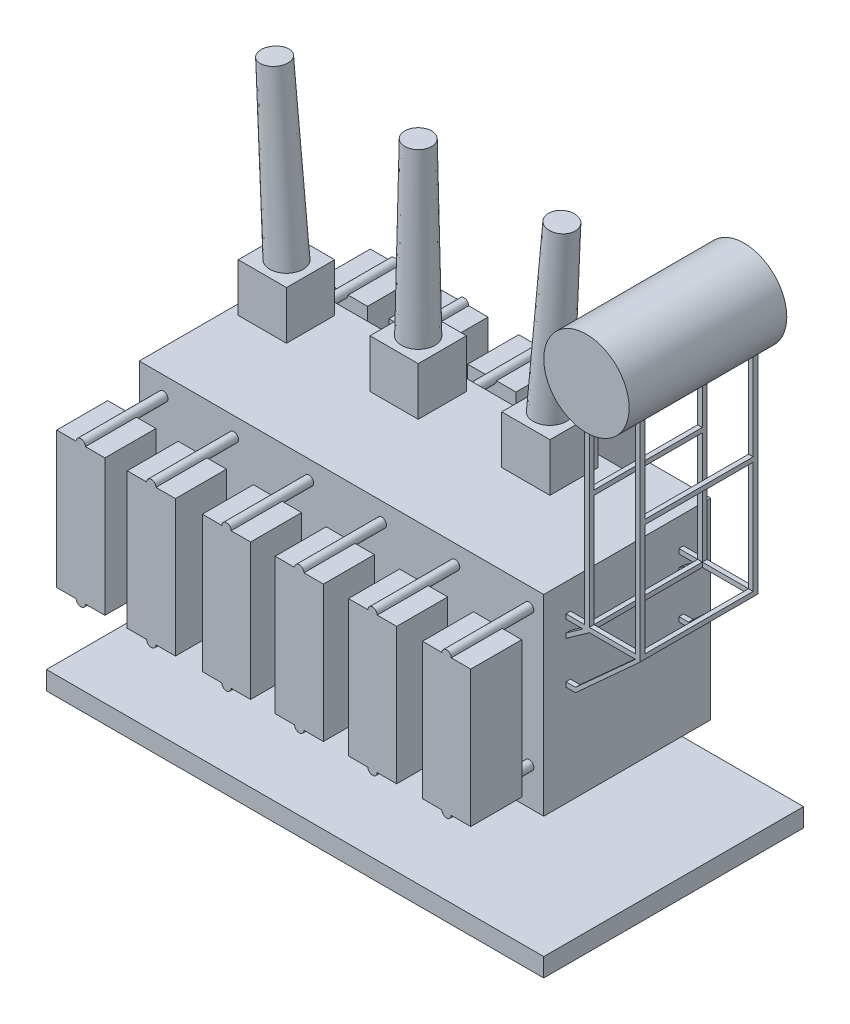
from build123d import *

# Parameters (mm, degrees)
BOSS_EXTRUDE1_DEPTH   = 1800
SKETCH3_W             = 3700
SKETCH3_H             = 199.704337058
CUT_EXTRUDE1_DEPTH    = 1800
SKETCH5_W             = 3700
SKETCH5_H             = 199.704337058
CUT_EXTRUDE2_DEPTH    = 1800
SKETCH6_W             = 520
SKETCH6_H             = 550
BOSS_EXTRUDE2_DEPTH   = 1470
BOSS_EXTRUDE2_2_DEPTH = 1470
BOSS_EXTRUDE2_3_DEPTH = 1470
BOSS_EXTRUDE2_4_DEPTH = 1470
BOSS_EXTRUDE2_5_DEPTH = 1470
BOSS_EXTRUDE2_6_DEPTH = 1470
SKETCH7_W             = 520
SKETCH7_H             = 550
BOSS_EXTRUDE3_DEPTH   = 1470
BOSS_EXTRUDE3_2_DEPTH = 1470
BOSS_EXTRUDE3_3_DEPTH = 1470
BOSS_EXTRUDE3_4_DEPTH = 1470
CUT_EXTRUDE3_DEPTH    = 2761
BOSS_EXTRUDE4_DEPTH   = 200
BOSS_EXTRUDE5_START   = -890
SKETCH9_R             = 50
BOSS_EXTRUDE5_DEPTH   = 890
BOSS_EXTRUDE6_START   = -890
SKETCH12_R            = 50
BOSS_EXTRUDE6_DEPTH   = 890
BOSS_EXTRUDE7_REACH   = 6057.333
SKETCH13_R            = 50
SKETCH15_W            = 520
SKETCH15_H            = 520
SKETCH15_W_2          = 519.994242444
SKETCH15_H_2          = 519.994242444
BOSS_EXTRUDE8_DEPTH   = 520
SKETCH20_R            = 460
BOSS_EXTRUDE9_DEPTH   = 1700
SKETCH21_W            = 50
SKETCH21_H            = 50
BOSS_EXTRUDE10_DEPTH  = 800
BOSS_EXTRUDE12_DEPTH  = 50
BOSS_EXTRUDE13_DEPTH  = 50
BOSS_EXTRUDE14_REACH  = 7096.951
SKETCH26_W            = 50
SKETCH26_H            = 50.276711992
SKETCH26_H_2          = 50
BOSS_EXTRUDE15_REACH  = 7319.411
SKETCH27_W            = 50
SKETCH27_H            = 50
BOSS_EXTRUDE16_REACH  = 7319.411
SKETCH29_W            = 50
SKETCH29_H            = 50
SKETCH30_W            = 5360
SKETCH30_H            = 2800
BOSS_EXTRUDE17_DEPTH  = 200


with BuildPart() as part:
    # Sketch2 → Boss-Extrude1 (new body)
    with BuildSketch(Plane.XY):
        Polygon((-4370.870959495, 2277.123604061), (-10.870959495, 2277.123604061), (-10.870959495, 247.123604061), (-670.870959495, 247.123604061), (-670.870959495, 7.123604061), (-4370.870959495, 7.123604061), align=None)
    extrude(amount=BOSS_EXTRUDE1_DEPTH)

    # Sketch3 → Cut-Extrude1 (cut)
    with BuildSketch(Plane(origin=(0, 2277.123604061, 0), x_dir=(1, 0, 0), z_dir=(0, 1, 0))):
        with Locations((-2520.870959495, -99.852168529)):
            Rectangle(SKETCH3_W, SKETCH3_H)
    extrude(amount=-CUT_EXTRUDE1_DEPTH, mode=Mode.SUBTRACT)

    # Sketch5 → Cut-Extrude2 (cut)
    with BuildSketch(Plane(origin=(0, 477.123604061, 0), x_dir=(1, 0, 0), z_dir=(0, 1, 0))):
        with Locations((-2520.870959495, -99.852168529)):
            Rectangle(SKETCH5_W, SKETCH5_H)
    extrude(amount=-CUT_EXTRUDE2_DEPTH, mode=Mode.SUBTRACT)

    # Sketch10 → Cut-Extrude3 (cut)
    with BuildSketch(Plane.XY.offset(1800)):
        Polygon((-4370.870959495, 7.123604061), (-4370.870959495, 207.123604061), (-670.870959495, 207.123604061), (-670.870959495, 407.123604061), (-10.870959495, 407.123604061), (-10.870959495, -217.1470637), (-4370.870959495, -217.1470637), align=None)
    extrude(amount=-CUT_EXTRUDE3_DEPTH, mode=Mode.SUBTRACT)

    # Sketch11 → Boss-Extrude4 (add)
    with BuildSketch(Plane(origin=(0, 2277.123604061, 0), x_dir=(1, 0, 0), z_dir=(0, 1, 0))):
        Polygon((-4370.870959495, -199.704337058), (-670.870959495, -199.704337058), (-670.870959495, 0), (-10.870959495, 0), (-10.870959495, -1800), (-4370.870959495, -1800), align=None)
    extrude(amount=BOSS_EXTRUDE4_DEPTH)



with BuildPart() as body_2:
    # Sketch6 → Boss-Extrude2 (new body)
    with BuildSketch(Plane(origin=(0, 2277.123604061, 0), x_dir=(1, 0, 0), z_dir=(0, 1, 0))):
        with Locations((-4110.870959495, -2415)):
            Rectangle(SKETCH6_W, SKETCH6_H)
    extrude(amount=-BOSS_EXTRUDE2_DEPTH)


with BuildPart() as body_3:
    # Sketch6 → Boss-Extrude2 2 (new body)
    with BuildSketch(Plane(origin=(0, 2277.123604061, 0), x_dir=(1, 0, 0), z_dir=(0, 1, 0))):
        with Locations((-3350.870959495, -2415)):
            Rectangle(SKETCH6_W, SKETCH6_H)
    extrude(amount=-BOSS_EXTRUDE2_2_DEPTH)


with BuildPart() as body_4:
    # Sketch6 → Boss-Extrude2 3 (new body)
    with BuildSketch(Plane(origin=(0, 2277.123604061, 0), x_dir=(1, 0, 0), z_dir=(0, 1, 0))):
        with Locations((-2540.870959495, -2415)):
            Rectangle(SKETCH6_W, SKETCH6_H)
    extrude(amount=-BOSS_EXTRUDE2_3_DEPTH)


with BuildPart() as body_5:
    # Sketch6 → Boss-Extrude2 4 (new body)
    with BuildSketch(Plane(origin=(0, 2277.123604061, 0), x_dir=(1, 0, 0), z_dir=(0, 1, 0))):
        with Locations((-1755.870959495, -2415)):
            Rectangle(SKETCH6_W, SKETCH6_H)
    extrude(amount=-BOSS_EXTRUDE2_4_DEPTH)


with BuildPart() as body_6:
    # Sketch6 → Boss-Extrude2 5 (new body)
    with BuildSketch(Plane(origin=(0, 2277.123604061, 0), x_dir=(1, 0, 0), z_dir=(0, 1, 0))):
        with Locations((-965.870959495, -2415)):
            Rectangle(SKETCH6_W, SKETCH6_H)
    extrude(amount=-BOSS_EXTRUDE2_5_DEPTH)


with BuildPart() as body_7:
    # Sketch6 → Boss-Extrude2 6 (new body)
    with BuildSketch(Plane(origin=(0, 2277.123604061, 0), x_dir=(1, 0, 0), z_dir=(0, 1, 0))):
        with Locations((-167.870959495, -2415)):
            Rectangle(SKETCH6_W, SKETCH6_H)
    extrude(amount=-BOSS_EXTRUDE2_6_DEPTH)


with BuildPart() as body_8:
    # Sketch7 → Boss-Extrude3 (new body)
    with BuildSketch(Plane(origin=(0, 2277.123604061, 0), x_dir=(1, 0, 0), z_dir=(0, 1, 0))):
        with Locations((-4110.870959495, 415.295662942)):
            Rectangle(SKETCH7_W, SKETCH7_H)
    extrude(amount=-BOSS_EXTRUDE3_DEPTH)


with BuildPart() as body_9:
    # Sketch7 → Boss-Extrude3 2 (new body)
    with BuildSketch(Plane(origin=(0, 2277.123604061, 0), x_dir=(1, 0, 0), z_dir=(0, 1, 0))):
        with Locations((-3360.870959495, 415.295662942)):
            Rectangle(SKETCH7_W, SKETCH7_H)
    extrude(amount=-BOSS_EXTRUDE3_2_DEPTH)


with BuildPart() as body_10:
    # Sketch7 → Boss-Extrude3 3 (new body)
    with BuildSketch(Plane(origin=(0, 2277.123604061, 0), x_dir=(1, 0, 0), z_dir=(0, 1, 0))):
        with Locations((-2510.870959495, 415.295662942)):
            Rectangle(SKETCH7_W, SKETCH7_H)
    extrude(amount=-BOSS_EXTRUDE3_3_DEPTH)


with BuildPart() as body_11:
    # Sketch7 → Boss-Extrude3 4 (new body)
    with BuildSketch(Plane(origin=(0, 2277.123604061, 0), x_dir=(1, 0, 0), z_dir=(0, 1, 0))):
        with Locations((-1770.870959495, 415.295662942)):
            Rectangle(SKETCH7_W, SKETCH7_H)
    extrude(amount=-BOSS_EXTRUDE3_4_DEPTH)


with BuildPart() as part_1:
    add(part.part)

    add(body_2.part)  # Boss-Extrude5 merges body 2

    add(body_3.part)  # Boss-Extrude5 merges body 3

    add(body_4.part)  # Boss-Extrude5 merges body 4

    add(body_5.part)  # Boss-Extrude5 merges body 5

    add(body_6.part)  # Boss-Extrude5 merges body 6

    add(body_7.part)  # Boss-Extrude5 merges body 7
    # Sketch9 → Boss-Extrude5 (add)
    with BuildSketch(Plane.XY.offset(2690).offset(BOSS_EXTRUDE5_START)):
        with Locations((-4110.870959495, 2277.123604061)):
            Circle(SKETCH9_R)
        with Locations((-3350.870959495, 2277.123604061)):
            Circle(SKETCH9_R)
        with Locations((-2540.870959495, 2277.123604061)):
            Circle(SKETCH9_R)
        with Locations((-1755.870959495, 2277.123604061)):
            Circle(SKETCH9_R)
        with Locations((-965.870959495, 2277.123604061)):
            Circle(SKETCH9_R)
        with Locations((-167.870959495, 2277.123604061)):
            Circle(SKETCH9_R)
    extrude(amount=BOSS_EXTRUDE5_DEPTH)


    add(body_8.part)  # Boss-Extrude6 merges body 8

    add(body_9.part)  # Boss-Extrude6 merges body 9

    add(body_10.part)  # Boss-Extrude6 merges body 10

    add(body_11.part)  # Boss-Extrude6 merges body 11
    # Sketch12 → Boss-Extrude6 (add)
    with BuildSketch(Plane(origin=(0, 0, -690.295662942), x_dir=(-1, 0, 0), z_dir=(0, 0, -1)).offset(BOSS_EXTRUDE6_START)):
        with Locations((1770.870959495, 2277.123604061)):
            Circle(SKETCH12_R)
        with Locations((2510.870959495, 2277.123604061)):
            Circle(SKETCH12_R)
        with Locations((3360.870959495, 2277.123604061)):
            Circle(SKETCH12_R)
        with Locations(Location((4110.870959495, 2277.123604061, 0), (0, 0, 180))):
            Circle(SKETCH12_R)
        with Locations(Location((4110.870959495, 807.123604061, 0), (0, 0, 180))):
            Circle(SKETCH12_R)
        with Locations((3360.870959495, 807.123604061)):
            Circle(SKETCH12_R)
        with Locations((2510.870959495, 807.123604061)):
            Circle(SKETCH12_R)
        with Locations((1770.870959495, 807.123604061)):
            Circle(SKETCH12_R)
    extrude(amount=BOSS_EXTRUDE6_DEPTH)

    # Sketch13 → Boss-Extrude7 (add, up to next)
    with BuildSketch(Plane.XY.offset(2690), mode=Mode.PRIVATE) as boss_extrude7_sk1:
        with Locations((-4110.870959495, 807.123604061)):
            Circle(SKETCH13_R)
    boss_extrude7_tool1 = extrude(boss_extrude7_sk1.sketch, amount=-BOSS_EXTRUDE7_REACH, mode=Mode.PRIVATE) - part_1.part
    # Sketch13 → Boss-Extrude7 (add, up to next)
    with BuildSketch(Plane.XY.offset(2690), mode=Mode.PRIVATE) as boss_extrude7_sk2:
        with Locations((-3350.870959495, 807.123604061)):
            Circle(SKETCH13_R)
    boss_extrude7_tool2 = extrude(boss_extrude7_sk2.sketch, amount=-BOSS_EXTRUDE7_REACH, mode=Mode.PRIVATE) - part_1.part
    # Sketch13 → Boss-Extrude7 (add, up to next)
    with BuildSketch(Plane.XY.offset(2690), mode=Mode.PRIVATE) as boss_extrude7_sk3:
        with Locations((-2540.870959495, 807.123604061)):
            Circle(SKETCH13_R)
    boss_extrude7_tool3 = extrude(boss_extrude7_sk3.sketch, amount=-BOSS_EXTRUDE7_REACH, mode=Mode.PRIVATE) - part_1.part
    # Sketch13 → Boss-Extrude7 (add, up to next)
    with BuildSketch(Plane.XY.offset(2690), mode=Mode.PRIVATE) as boss_extrude7_sk4:
        with Locations((-1755.870959495, 807.123604061)):
            Circle(SKETCH13_R)
    boss_extrude7_tool4 = extrude(boss_extrude7_sk4.sketch, amount=-BOSS_EXTRUDE7_REACH, mode=Mode.PRIVATE) - part_1.part
    # Sketch13 → Boss-Extrude7 (add, up to next)
    with BuildSketch(Plane.XY.offset(2690), mode=Mode.PRIVATE) as boss_extrude7_sk5:
        with Locations((-965.870959495, 807.123604061)):
            Circle(SKETCH13_R)
    boss_extrude7_tool5 = extrude(boss_extrude7_sk5.sketch, amount=-BOSS_EXTRUDE7_REACH, mode=Mode.PRIVATE) - part_1.part
    # Sketch13 → Boss-Extrude7 (add, up to next)
    with BuildSketch(Plane.XY.offset(2690), mode=Mode.PRIVATE) as boss_extrude7_sk6:
        with Locations((-167.870959495, 807.123604061)):
            Circle(SKETCH13_R)
    boss_extrude7_tool6 = extrude(boss_extrude7_sk6.sketch, amount=-BOSS_EXTRUDE7_REACH, mode=Mode.PRIVATE) - part_1.part
    add(boss_extrude7_tool1.solids().sort_by_distance((-4110.870959, 807.123604, 2690))[0])
    add(boss_extrude7_tool2.solids().sort_by_distance((-3350.870959, 807.123604, 2690))[0])
    add(boss_extrude7_tool3.solids().sort_by_distance((-2540.870959, 807.123604, 2690))[0])
    add(boss_extrude7_tool4.solids().sort_by_distance((-1755.870959, 807.123604, 2690))[0])
    add(boss_extrude7_tool5.solids().sort_by_distance((-965.870959, 807.123604, 2690))[0])
    add(boss_extrude7_tool6.solids().sort_by_distance((-167.870959, 807.123604, 2690))[0])

    # Sketch15 → Boss-Extrude8 (add)
    with BuildSketch(Plane(origin=(0, 2477.123604061, 0), x_dir=(1, 0, 0), z_dir=(0, 1, 0))):
        with Locations((-4002.561428397, -581.333533477)):
            Rectangle(SKETCH15_W, SKETCH15_H)
        with Locations((-1162.592873509, -581.333533477)):
            Rectangle(SKETCH15_W_2, SKETCH15_H_2)
        with Locations((-2582.577150953, -581.333533477)):
            Rectangle(SKETCH15_W_2, SKETCH15_H_2)
    extrude(amount=BOSS_EXTRUDE8_DEPTH)

    # Sketch19 → Revolve4 (revolve)
    with BuildSketch(Plane.XY.offset(581.333533477)):
        Polygon((-4002.561428397, 2997.123604061), (-4130.913340086, 4832.641456539), (-3986.266552798, 4842.756145232), (-3822.561428397, 2997.123604061), align=None)
    revolve(axis=Axis((-4002.561428397, 2997.123604061, 581.333533477), (-0.06975647374413482, 0.9975640502598236, 0)))

    # Sketch19_6 → Revolve5 (revolve)
    with BuildSketch(Plane.XY.offset(581.333533477), mode=Mode.PRIVATE) as revolve5_sk:
        Polygon((-2582.577150953, 2997.123604061), (-2402.577150953, 2997.123604061), (-2437.577150953, 4837.123604061), (-2582.577150953, 4837.123604061), align=None)
    revolve(revolve5_sk.sketch.rotate(Axis((-2582.577150953, 2997.123604061, 581.333533477), (0, 1, 0)), 90), axis=Axis((-2582.577150953, 2997.123604061, 581.333533477), (0, 1, 0)))

    # Sketch19_7 → Revolve6 (revolve)
    with BuildSketch(Plane.XY.offset(581.333533477), mode=Mode.PRIVATE) as revolve6_sk:
        Polygon((-1342.592873509, 2997.123604061), (-1178.887749108, 4842.756145232), (-1034.24096182, 4832.641456539), (-1162.592873509, 2997.123604061), align=None)
    revolve(revolve6_sk.sketch.rotate(Axis((-1162.592873509, 2997.123604061, 581.333533477), (0.06975647374413482, 0.9975640502598236, 0)), 180), axis=Axis((-1162.592873509, 2997.123604061, 581.333533477), (0.06975647374413482, 0.9975640502598236, 0)))

    # Sketch21 → Boss-Extrude10 (add)
    with BuildSketch(Plane(origin=(-10.870959495, 0, 0), x_dir=(0, 0, -1), z_dir=(1, 0, 0))):
        with Locations((-317.282854415, 2152.123604061)):
            Rectangle(SKETCH21_W, SKETCH21_H)
        with Locations((-1535.562634281, 2152.123604061)):
            Rectangle(SKETCH21_W, SKETCH21_H)
    extrude(amount=BOSS_EXTRUDE10_DEPTH)



with BuildPart() as body_2_2:
    # Sketch20 → Boss-Extrude9 (new body)
    with BuildSketch(Plane.XY.offset(1800)):
        with Locations((449.129040505, 4677.123604061)):
            Circle(SKETCH20_R)
    extrude(amount=-BOSS_EXTRUDE9_DEPTH)


with BuildPart() as part_2:
    add(part_1.part)

    add(body_2_2.part)  # Boss-Extrude12 merges body 2 2
    # Sketch22 → Boss-Extrude12 (add)
    with BuildSketch(Plane(origin=(0, 0, 292.282854415), x_dir=(-1, 0, 0), z_dir=(0, 0, -1))):
        with BuildLine():
            Line((-789.129040505, 2177.123604061), (-789.129040505, 4367.284936364))
            ThreePointArc((-789.129040505, 4367.284936364), (-765.01309084, 4342.732714915), (-739.129040505, 4320.052182634))
            Line((-739.129040505, 4320.052182634), (-739.129040505, 2177.123604061))
            Line((-739.129040505, 2177.123604061), (-789.129040505, 2177.123604061))
        make_face()
        with BuildLine():
            Line((-190.763623347, 2177.123604061), (-190.763623347, 4296.53549177))
            ThreePointArc((-190.763623347, 4296.53549177), (-215.297500799, 4280.988764595), (-240.763623347, 4267.021357136))
            Line((-240.763623347, 4267.021357136), (-240.763623347, 2177.123604061))
            Line((-240.763623347, 2177.123604061), (-190.763623347, 2177.123604061))
        make_face()
        Polygon((-789.129040505, 2127.123604061), (-739.129040505, 2127.123604061), (-92.129040505, 1542.123604061), (-92.129040505, 1492.123604061), align=None)
        Polygon((-170.670826241, 2127.123604061), (-240.763623347, 2127.123604061), (10.870959495, 1947.622575973), (10.870959495, 1997.622575973), align=None)
    extrude(amount=-BOSS_EXTRUDE12_DEPTH)

    # Sketch25 → Boss-Extrude13 (add)
    with BuildSketch(Plane.XY.offset(1560.562634281)):
        Polygon((240.763623347, 2127.123604061), (170.670826241, 2127.123604061), (-10.870959495, 1997.622575973), (-10.870959495, 1947.622575973), align=None)
        with BuildLine():
            Line((190.763623347, 2177.123604061), (240.763623347, 2177.123604061))
            Line((240.763623347, 2177.123604061), (240.763623347, 4267.021357136))
            ThreePointArc((240.763623347, 4267.021357136), (215.297500799, 4280.988764595), (190.763623347, 4296.53549177))
            Line((190.763623347, 4296.53549177), (190.763623347, 2177.123604061))
        make_face()
        Polygon((789.129040505, 2127.123604061), (739.129040505, 2127.123604061), (92.129040505, 1542.123604061), (92.129040505, 1492.123604061), align=None)
        with BuildLine():
            Line((739.129040505, 2177.123604061), (789.129040505, 2177.123604061))
            Line((789.129040505, 2177.123604061), (789.129040505, 4367.284936364))
            ThreePointArc((789.129040505, 4367.284936364), (765.01309084, 4342.732714915), (739.129040505, 4320.052182634))
            Line((739.129040505, 4320.052182634), (739.129040505, 2177.123604061))
        make_face()
    extrude(amount=-BOSS_EXTRUDE13_DEPTH)

    # Sketch26 → Boss-Extrude14 (add, up to next)
    with BuildSketch(Plane(origin=(0, 0, 1510.562634281), x_dir=(-1, 0, 0), z_dir=(0, 0, -1)), mode=Mode.PRIVATE) as boss_extrude14_sk1:
        with Locations((-764.129040505, 2152.261960057)):
            Rectangle(SKETCH26_W, SKETCH26_H)
    boss_extrude14_tool1 = extrude(boss_extrude14_sk1.sketch, amount=BOSS_EXTRUDE14_REACH, mode=Mode.PRIVATE) - part_2.part
    # Sketch26 → Boss-Extrude14 (add, up to next)
    with BuildSketch(Plane(origin=(0, 0, 1510.562634281), x_dir=(-1, 0, 0), z_dir=(0, 0, -1)), mode=Mode.PRIVATE) as boss_extrude14_sk2:
        with Locations((-215.763623347, 2152.123604061)):
            Rectangle(SKETCH26_W, SKETCH26_H_2)
    boss_extrude14_tool2 = extrude(boss_extrude14_sk2.sketch, amount=BOSS_EXTRUDE14_REACH, mode=Mode.PRIVATE) - part_2.part
    # Sketch26 → Boss-Extrude14 (add, up to next)
    with BuildSketch(Plane(origin=(0, 0, 1510.562634281), x_dir=(-1, 0, 0), z_dir=(0, 0, -1)), mode=Mode.PRIVATE) as boss_extrude14_sk3:
        with Locations((-764.129040505, 3408.38013604)):
            Rectangle(SKETCH26_W, SKETCH26_H_2)
    boss_extrude14_tool3 = extrude(boss_extrude14_sk3.sketch, amount=BOSS_EXTRUDE14_REACH, mode=Mode.PRIVATE) - part_2.part
    # Sketch26 → Boss-Extrude14 (add, up to next)
    with BuildSketch(Plane(origin=(0, 0, 1510.562634281), x_dir=(-1, 0, 0), z_dir=(0, 0, -1)), mode=Mode.PRIVATE) as boss_extrude14_sk4:
        with Locations((-215.763623347, 3408.38013604)):
            Rectangle(SKETCH26_W, SKETCH26_H_2)
    boss_extrude14_tool4 = extrude(boss_extrude14_sk4.sketch, amount=BOSS_EXTRUDE14_REACH, mode=Mode.PRIVATE) - part_2.part
    add(boss_extrude14_tool1.solids().sort_by_distance((764.129041, 2152.26196, 1510.562634))[0])
    add(boss_extrude14_tool2.solids().sort_by_distance((215.763623, 2152.123604, 1510.562634))[0])
    add(boss_extrude14_tool3.solids().sort_by_distance((764.129041, 3408.380136, 1510.562634))[0])
    add(boss_extrude14_tool4.solids().sort_by_distance((215.763623, 3408.380136, 1510.562634))[0])

    # Sketch27 → Boss-Extrude15 (add, up to next)
    with BuildSketch(Plane.ZY.offset(-92.129040505), mode=Mode.PRIVATE) as boss_extrude15_sk1:
        with Locations((317.282854415, 1517.123604061)):
            Rectangle(SKETCH27_W, SKETCH27_H)
    boss_extrude15_tool1 = extrude(boss_extrude15_sk1.sketch, amount=BOSS_EXTRUDE15_REACH, mode=Mode.PRIVATE) - part_2.part
    add(boss_extrude15_tool1.solids().sort_by_distance((92.129041, 1517.123604, 317.282854))[0])

    # Sketch29 → Boss-Extrude16 (add, up to next)
    with BuildSketch(Plane.ZY.offset(-92.129040505), mode=Mode.PRIVATE) as boss_extrude16_sk1:
        with Locations((1535.562634281, 1517.123604061)):
            Rectangle(SKETCH29_W, SKETCH29_H)
    boss_extrude16_tool1 = extrude(boss_extrude16_sk1.sketch, amount=BOSS_EXTRUDE16_REACH, mode=Mode.PRIVATE) - part_2.part
    add(boss_extrude16_tool1.solids().sort_by_distance((92.129041, 1517.123604, 1535.562634))[0])


with BuildPart() as body_2_3:
    # Sketch30 → Boss-Extrude17 (new body)
    with BuildSketch(Plane(origin=(0, -402.876395939, 0), x_dir=(-1, 0, 0), z_dir=(0, -1, 0))):
        with Locations((2190.870959495, -900)):
            Rectangle(SKETCH30_W, SKETCH30_H)
    extrude(amount=BOSS_EXTRUDE17_DEPTH)


solid = Compound([part_2.part, body_2_3.part])
